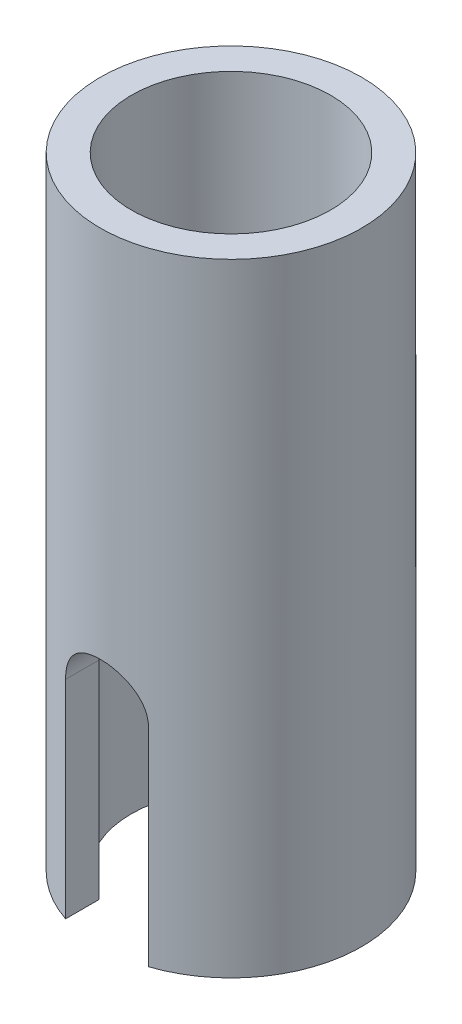
from build123d import *

# Parameters (mm, degrees)
ESQUISSE1_W                  = 1.5
ESQUISSE1_H                  = 30
ENL_V_MAT_EXTRU_1_DEPTH      = 7.3
ENL_V_MAT_EXTRU_1_DEPTH_BACK = 7.3


with BuildPart() as part:
    # Esquisse1 → Révolution1 (revolve)
    with BuildSketch(Plane.XY):
        with Locations((5.55, 15)):
            Rectangle(ESQUISSE1_W, ESQUISSE1_H)
    revolve(axis=Axis((0, 0, 0), (0, 1, 0)))

    # Esquisse2 → Enlèv. mat.-Extru.1 (cut, two sides)
    with BuildSketch(Plane.XY) as enl_v_mat_extru_1_sk:
        with BuildLine():
            Line((-2, -10), (-2, 10))
            ThreePointArc((-2, 10), (0, 12), (2, 10))
            Line((2, 10), (2, -10))
            ThreePointArc((2, -10), (0, -12), (-2, -10))
        make_face()
    extrude(amount=ENL_V_MAT_EXTRU_1_DEPTH, mode=Mode.SUBTRACT)
    extrude(enl_v_mat_extru_1_sk.sketch, amount=-ENL_V_MAT_EXTRU_1_DEPTH_BACK, mode=Mode.SUBTRACT)


solid = part.part
